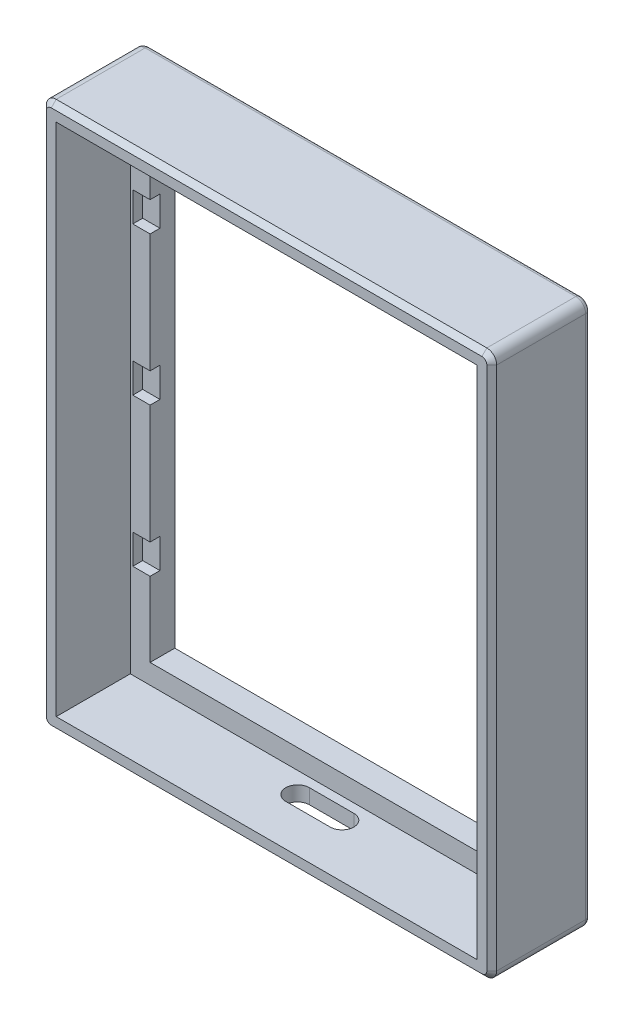
from build123d import *

# Parameters (mm, degrees)
MODEL_W             = 85.14935
MODEL_H             = 104.19946
MODEL_W_2           = 77.14935
MODEL_H_2           = 96.19946
EXTRUDE_2_DEPTH     = 5
SKETCH_2_W          = 3.5
SKETCH_2_H          = 6
CUT_EXTRUDE_1_DEPTH = 2
SKETCH_4_W          = 91.14935
SKETCH_4_H          = 110.19946
SKETCH_4_W_2        = 85.14935
SKETCH_4_H_2        = 104.19946
EXTRUDE_5_DEPTH     = 20
FILLET_1_R          = 2
CHAMFER_1_SIZE      = 1
FILLET_2_R          = 1
CUT_EXTRUDE_2_DEPTH = 10


with BuildPart() as part:
    # Model → 凸台-拉伸2 (new body)
    with BuildSketch(Plane.XY):
        with Locations((38.194325, 47.88337)):
            Rectangle(MODEL_W, MODEL_H)
        with Locations((38.194325, 47.88337)):
            Rectangle(MODEL_W_2, MODEL_H_2, mode=Mode.SUBTRACT)
    extrude(amount=EXTRUDE_2_DEPTH)

    # 草图2 → 切除-拉伸1 (cut)
    with BuildSketch(Plane.XY.offset(5)):
        with Locations((-2.13035, 77.88337)):
            Rectangle(SKETCH_2_W, SKETCH_2_H)
        with Locations((78.519, 77.88337)):
            Rectangle(SKETCH_2_W, SKETCH_2_H)
        with Locations((-2.13035, 47.88337)):
            Rectangle(SKETCH_2_W, SKETCH_2_H)
        with Locations((78.519, 47.88337)):
            Rectangle(SKETCH_2_W, SKETCH_2_H)
        with Locations((-2.13035, 17.88337)):
            Rectangle(SKETCH_2_W, SKETCH_2_H)
        with Locations((78.519, 17.88337)):
            Rectangle(SKETCH_2_W, SKETCH_2_H)
    extrude(amount=-CUT_EXTRUDE_1_DEPTH, mode=Mode.SUBTRACT)

    # 草图4 → 凸台-拉伸5 (add)
    with BuildSketch(Plane(origin=(0, 0, 0), x_dir=(-1, 0, 0), z_dir=(0, 0, -1))):
        with Locations((-38.194325, 47.88337)):
            Rectangle(SKETCH_4_W, SKETCH_4_H)
        with Locations((-38.194325, 47.88337)):
            Rectangle(SKETCH_4_W_2, SKETCH_4_H_2, mode=Mode.SUBTRACT)
    extrude(amount=-EXTRUDE_5_DEPTH)

    # 圆角1
    fillet_1_edges = [part.edges().sort_by_distance(p)[0] for p in [
        (83.769, 102.9831, 10),
        (-7.38035, 102.9831, 10),
        (-7.38035, -7.21636, 10),
        (83.769, -7.21636, 10),
    ]]
    fillet(fillet_1_edges, radius=FILLET_1_R)

    # 倒角1
    chamfer_1_edges = [part.edges().sort_by_distance(p)[0] for p in [
        (-7.38035, 47.88337, 20),
        (38.194325, 102.9831, 20),
        (38.194325, -7.21636, 20),
        (83.769, 47.88337, 20),
        (-6.794563562, -6.630573562, 20),
        (83.183213562, -6.630573562, 20),
        (83.183213562, 102.397313562, 20),
        (-6.794563562, 102.397313562, 20),
    ]]
    chamfer(chamfer_1_edges, length=CHAMFER_1_SIZE)

    # 圆角2
    fillet_2_edges = [part.edges().sort_by_distance(p)[0] for p in [
        (-7.38035, 47.88337, 0),
        (38.194325, 102.9831, 0),
        (83.769, 47.88337, 0),
        (38.194325, -7.21636, 0),
        (-6.794563562, -6.630573562, 0),
        (83.183213562, -6.630573562, 0),
        (83.183213562, 102.397313562, 0),
        (-6.794563562, 102.397313562, 0),
    ]]
    fillet(fillet_2_edges, radius=FILLET_2_R)

    # 草图5 → 切除-拉伸2 (cut)
    with BuildSketch(Plane(origin=(76.38865, -7.21636, 20), x_dir=(-1, 0, 0), z_dir=(0, -1, 0))):
        with BuildLine():
            Line((33.694325, 13.169990539), (42.694325, 13.169990539))
            ThreePointArc((42.694325, 13.169990539), (45.094325, 10.769990539), (42.694325, 8.369990539))
            Line((42.694325, 8.369990539), (33.694325, 8.369990539))
            ThreePointArc((33.694325, 8.369990539), (31.294325, 10.769990539), (33.694325, 13.169990539))
        make_face()
    extrude(amount=-CUT_EXTRUDE_2_DEPTH, mode=Mode.SUBTRACT)


solid = part.part
